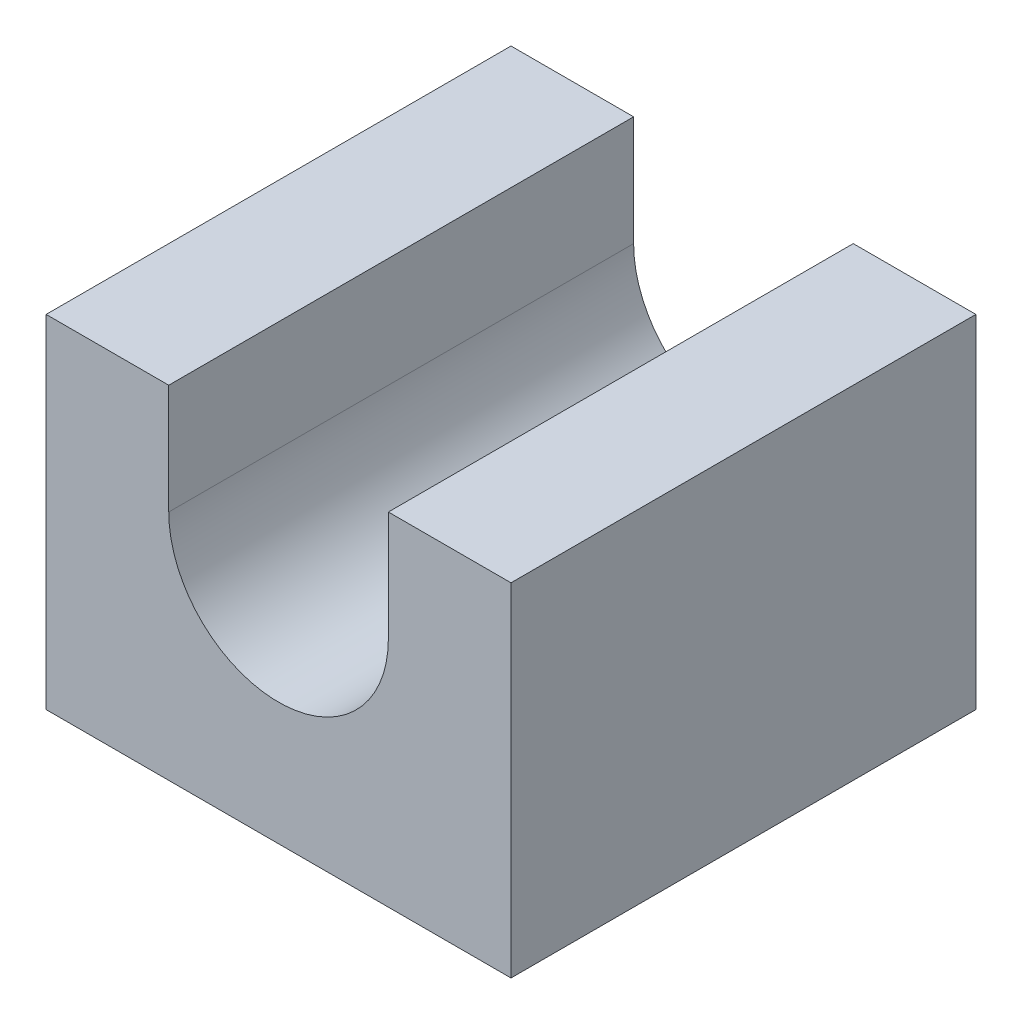
from build123d import *

# Parameters (mm, degrees)
BOSS_EXTRUDE2_DEPTH = 31.75


with BuildPart() as part:
    # Sketch2 → Boss-Extrude2 (new body)
    with BuildSketch(Plane.XY):
        with BuildLine():
            Line((8.375, 15.875), (8.375, 23.375))
            Line((8.375, 23.375), (0, 23.375))
            Line((0, 23.375), (0, 0))
            Line((0, 0), (31.75, 0))
            Line((31.75, 0), (31.75, 23.375))
            Line((31.75, 23.375), (23.375, 23.375))
            Line((23.375, 23.375), (23.375, 15.875))
            ThreePointArc((23.375, 15.875), (15.875, 8.375), (8.375, 15.875))
        make_face()
    extrude(amount=BOSS_EXTRUDE2_DEPTH)


solid = part.part
